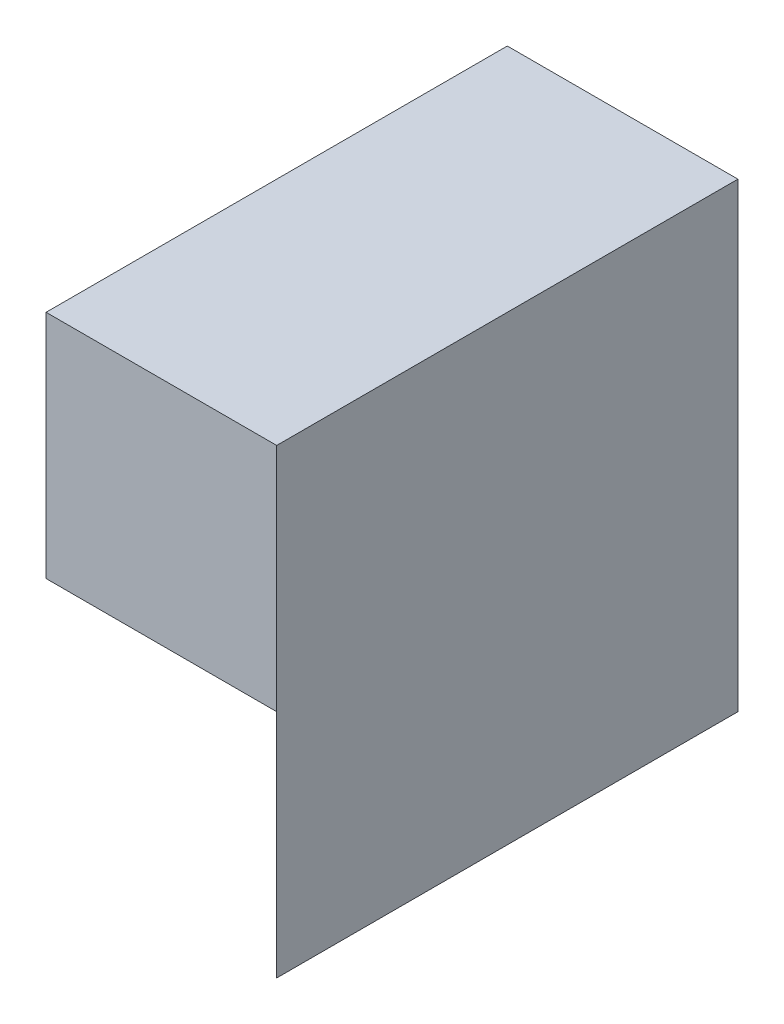
from build123d import *

# Parameters (mm, degrees)
SKETCH1_W           = 40
SKETCH1_H           = 20
BOSS_EXTRUDE1_DEPTH = 40
SKETCH2_W           = 20
SKETCH2_H           = 20
BOSS_EXTRUDE2_DEPTH = 40
CUT_EXTRUDE1_DEPTH  = 20
SKETCH4_W           = 40
SKETCH4_H           = 20
CUT_EXTRUDE2_DEPTH  = 35
CUT_EXTRUDE3_DEPTH  = 35
SKETCH6_W           = 20
SKETCH6_H           = 40
BOSS_EXTRUDE3_DEPTH = 20


with BuildPart() as part:
    # Sketch1 → Boss-Extrude1 (new body)
    with BuildSketch(Plane.XY):
        with Locations((20, 10)):
            Rectangle(SKETCH1_W, SKETCH1_H)
    extrude(amount=BOSS_EXTRUDE1_DEPTH)

    # Sketch2 → Boss-Extrude2 (add)
    with BuildSketch(Plane.XY.offset(40)):
        with Locations((30, 30)):
            Rectangle(SKETCH2_W, SKETCH2_H)
    extrude(amount=-BOSS_EXTRUDE2_DEPTH)

    # Sketch3 → Cut-Extrude1 (cut)
    with BuildSketch(Plane(origin=(0, 40, 0), x_dir=(1, 0, 0), z_dir=(0, 1, 0))):
        Polygon((20, -40), (40, -20), (40, -40), align=None)
    extrude(amount=-CUT_EXTRUDE1_DEPTH, mode=Mode.SUBTRACT)

    # Sketch4 → Cut-Extrude2 (cut)
    with BuildSketch(Plane.ZY.offset(-20)):
        with Locations((20, 30)):
            Rectangle(SKETCH4_W, SKETCH4_H)
    extrude(amount=-CUT_EXTRUDE2_DEPTH, mode=Mode.SUBTRACT)

    # Sketch5 → Cut-Extrude3 (cut)
    with BuildSketch(Plane(origin=(0, 20, 0), x_dir=(1, 0, 0), z_dir=(0, 1, 0))):
        Polygon((0, 0), (40, -40), (0, -40), align=None)
    extrude(amount=-CUT_EXTRUDE3_DEPTH, mode=Mode.SUBTRACT)

    # Sketch6 → Boss-Extrude3 (add)
    with BuildSketch(Plane(origin=(0, 20, 0), x_dir=(1, 0, 0), z_dir=(0, 1, 0))):
        with Locations((30, -20)):
            Rectangle(SKETCH6_W, SKETCH6_H)
    extrude(amount=BOSS_EXTRUDE3_DEPTH)


solid = part.part
